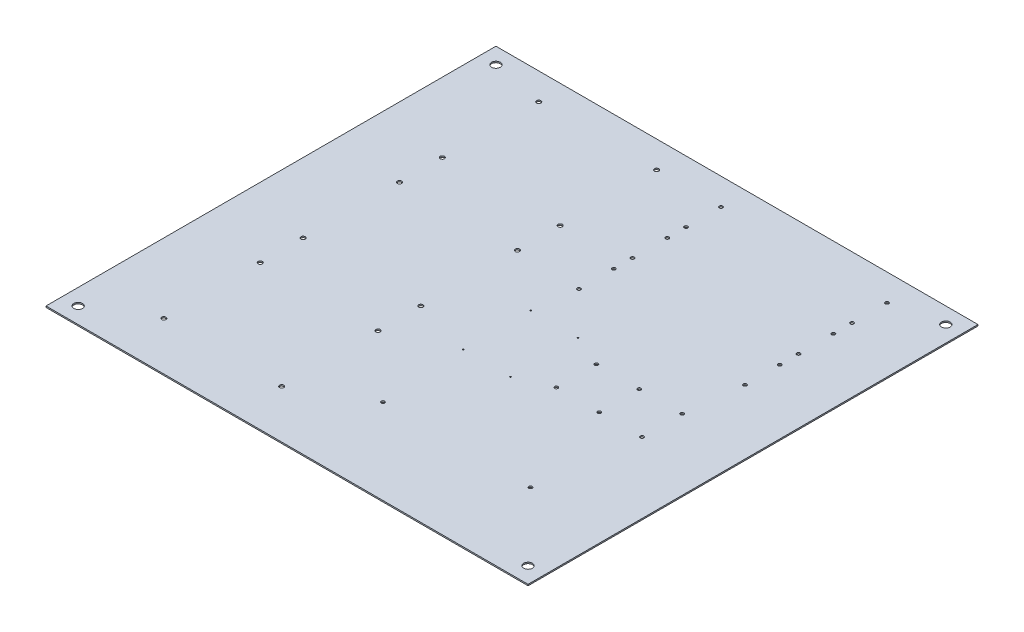
from build123d import *

# Parameters (mm, degrees)
SKETCH1_W               = 571.5
SKETCH1_H               = 533.4
BOSS_EXTRUDE1_DEPTH     = 1.5875
F_10_32_TAPPED_HOLE1_D  = 4.0386
F_1_4_20_TAPPED_HOLE1_D = 5.1054
M2X0_4_TAPPED_HOLE1_D   = 1.6
F_10_32_TAPPED_HOLE2_D  = 4.0386
F_10_32_TAPPED_HOLE3_D  = 4.0386
F_3_8_CLEARANCE_HOLE1_D = 10.31748


with BuildPart() as part:
    # Sketch1 → Boss-Extrude1 (new body)
    with BuildSketch(Plane(origin=(0, 0, 0), x_dir=(1, 0, 0), z_dir=(0, 1, 0))):
        with Locations((285.75, 266.7)):
            Rectangle(SKETCH1_W, SKETCH1_H)
    extrude(amount=BOSS_EXTRUDE1_DEPTH)

    # #10-32 Tapped Hole1 (through all)
    with Locations(Plane(origin=(0, 1.5875, 0), x_dir=(1, 0, 0), z_dir=(0, 1, 0))):
        with Locations((298.45, 501.65), (495.3, 501.65), (298.45, 460.375), (495.3, 460.375), (298.45, 438.15), (495.3, 438.15), (298.45, 396.875), (495.3, 396.875), (298.45, 374.65), (495.3, 374.65), (298.45, 333.375), (495.3, 333.375)):
            Hole(F_10_32_TAPPED_HOLE1_D / 2)

    # 1/4-20 Tapped Hole1 (through all)
    with Locations(Plane(origin=(0, 1.5875, 0), x_dir=(1, 0, 0), z_dir=(0, 1, 0))):
        with Locations((82.55, 501.65), (82.55, 387.35), (222.25, 387.35), (222.25, 501.65), (82.55, 336.55), (82.55, 222.25), (222.25, 222.25), (222.25, 336.55), (82.55, 171.45), (82.55, 57.15), (222.25, 57.15), (222.25, 171.45)):
            Hole(F_1_4_20_TAPPED_HOLE1_D / 2)

    # M2x0.4 Tapped Hole1 (through all)
    with Locations(Plane(origin=(0, 1.5875, 0), x_dir=(1, 0, 0), z_dir=(0, 1, 0))):
        with Locations((292.1, 282.575), (348.09999976, 282.575), (292.1, 202.575), (348.09999976, 202.575)):
            Hole(M2X0_4_TAPPED_HOLE1_D / 2)

    # #10-32 Tapped Hole2 (through all)
    with Locations(Plane(origin=(0, 1.5875, 0), x_dir=(1, 0, 0), z_dir=(0, 1, 0))):
        with Locations((386.19999976, 266.324), (386.19999976, 218.826), (436.99999976, 266.324), (436.99999976, 218.826), (487.79999976, 266.324), (487.79999976, 218.826)):
            Hole(F_10_32_TAPPED_HOLE2_D / 2)

    # #10-32 Tapped Hole3 (through all)
    with Locations(Plane(origin=(0, 1.5875, 0), x_dir=(1, 0, 0), z_dir=(0, 1, 0))):
        with Locations((298.45, 100.975), (473.456, 100.975)):
            Hole(F_10_32_TAPPED_HOLE3_D / 2)

    # 3/8 Clearance Hole1 (through all)
    with Locations(Plane(origin=(0, 1.5875, 0), x_dir=(1, 0, 0), z_dir=(0, 1, 0))):
        with Locations((19.05, 514.35), (552.45, 514.35), (552.45, 19.05), (19.05, 19.05)):
            Hole(F_3_8_CLEARANCE_HOLE1_D / 2)


solid = part.part
